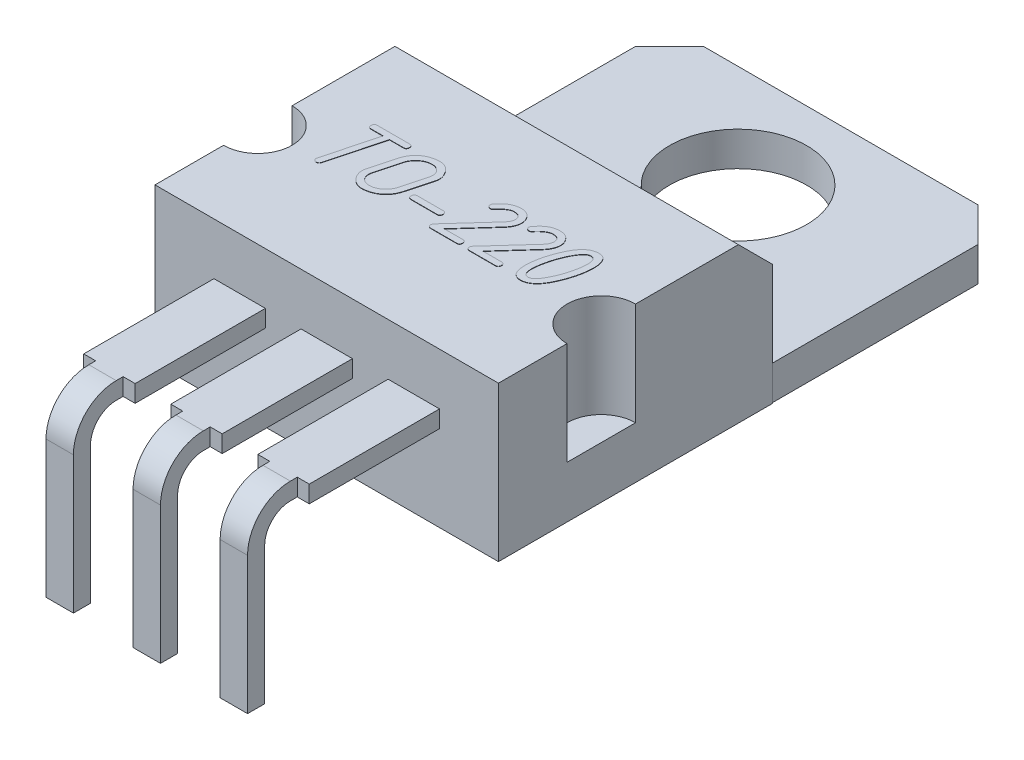
from build123d import *

# Parameters (mm, degrees)
SKETCH_1_R                 = 2
EXTRUDE_1_DEPTH            = 1
EXTRUDE_3_DEPTH            = 1.01
SKETCH_2_5_W               = 10.02
SKETCH_2_5_H               = 8
EXTRUDE_4_DEPTH            = 3.5
SKETCH_3_W                 = 1.5
SKETCH_3_H                 = 0.5
EXTRUDE_5_DEPTH            = 3.8
SKETCH_4_W                 = 0.8
SKETCH_4_H                 = 0.5
PATTERN_LINEAR_1_COUNT     = 2
PATTERN_LINEAR_1_PITCH     = 2.54
PATTERN_LINEAR_1_COL_COUNT = 2
PATTERN_LINEAR_1_COL_PITCH = 2.54
EXTRUDE_6_DEPTH            = 0.01
CHAMFER_1_SIZE             = 1
SKETCH_9_R                 = 1
CUT_EXTRUDE_1_DEPTH        = 3


with BuildPart() as part:
    # Sketch 1 → Extrude 1 (new body)
    with BuildSketch(Plane(origin=(0, 0, 0), x_dir=(1, 0, 0), z_dir=(0, 1, 0))):
        Polygon((0, 0), (8, 0), (8, 6), (9, 6), (9, 12), (8, 13), (0, 13), (-1, 12), (-1, 6), (0, 6), align=None)
        with Locations(Location((4, 10, 0), (0, 0, 270))):
            Circle(SKETCH_1_R, mode=Mode.SUBTRACT)
    extrude(amount=EXTRUDE_1_DEPTH)

    # Sketch 2 → Extrude 3 (add)
    with BuildSketch(Plane(origin=(0, 1, 0), x_dir=(1, 0, 0), z_dir=(0, 1, 0))):
        Polygon((0, 6), (-1.01, 6), (-1.01, -2), (9.01, -2), (9.01, 6), (8, 6), (8, 0), (0, 0), align=None)
    extrude(amount=-EXTRUDE_3_DEPTH)

    # Sketch 2_5 → Extrude 4 (add)
    with BuildSketch(Plane(origin=(0, 1, 0), x_dir=(1, 0, 0), z_dir=(0, 1, 0))):
        with Locations((4, 2)):
            Rectangle(SKETCH_2_5_W, SKETCH_2_5_H)
    extrude(amount=EXTRUDE_4_DEPTH)

    # Sketch 3 → Extrude 5 (add)
    with BuildSketch(Plane.XY.offset(2)):
        with Locations((4, 2.74)):
            Rectangle(SKETCH_3_W, SKETCH_3_H)
    extrude_5 = extrude(amount=EXTRUDE_5_DEPTH)

    # Sweep 1: sweep along a path in Sketch 7
    with BuildLine(Plane.ZY.offset(-4)) as sweep_1_path:
        Line((5.8, 2.74), (6, 2.74))
        ThreePointArc((6, 2.74), (6.707106781, 2.447106781), (7, 1.74))
        Line((7, 1.74), (7, -2.26))
    # Sketch 4 → Sweep 1 (sweep)
    with BuildSketch(Plane.XY.offset(5.8)):
        with Locations((4, 2.74)):
            Rectangle(SKETCH_4_W, SKETCH_4_H)
    sweep_1 = sweep(path=sweep_1_path.line)

    # Pattern Linear 1: Extrude 5, Sweep 1 ×2
    with Locations(*[(-i * PATTERN_LINEAR_1_PITCH, 0, 0) for i in range(1, PATTERN_LINEAR_1_COUNT)]):
        add(extrude_5)
        add(sweep_1)

    # Pattern Linear 1 col: Extrude 5, Sweep 1 ×2
    with Locations(*[(i * PATTERN_LINEAR_1_COL_PITCH, 0, 0) for i in range(1, PATTERN_LINEAR_1_COL_COUNT)]):
        add(extrude_5)
        add(sweep_1)

    # Sketch 8 → Extrude 6 (add)
    with BuildSketch(Plane(origin=(0, 4.5, 0), x_dir=(1, 0, 0), z_dir=(0, 1, 0))):
        with BuildLine():
            Line((1.27858567, 2.5547293), (0.859157599, 0.985020757))
            add(Edge.make_bspline(
                [(0.859157599, 0.985020757), (0.855633438, 0.974783342), (0.849087007, 0.955766466), (0.829278615, 0.93328717), (0.803143513, 0.919336806), (0.783409322, 0.918209838), (0.773079427, 0.917619925)],
                knots=[0, 0, 0, 0, 1.086908555, 2.019025704, 2.963055697, 4, 4, 4, 4], degree=3))
            add(Edge.make_bspline(
                [(0.773079427, 0.917619925), (0.767204868, 0.917864101), (0.755608941, 0.918346085), (0.739020981, 0.924335999), (0.722879767, 0.932189694), (0.708692809, 0.944021025), (0.696472399, 0.957627118), (0.687400283, 0.972740133), (0.681742621, 0.98896155), (0.681188277, 1.000135496), (0.680910819, 1.005728242)],
                knots=[0, 0, 0, 0, 0.998523784, 1.971008786, 2.984412935, 4.053273998, 5.101682541, 6.096988731, 7.047511114, 8, 8, 8, 8], degree=3))
            add(Edge.make_bspline(
                [(0.680910819, 1.005728242), (0.681174471, 1.010217201), (0.681723788, 1.019569906), (0.684127251, 1.028627792), (0.685377139, 1.033338221)],
                knots=[0, 0, 0, 0, 0.959927375, 2, 2, 2, 2], degree=3))
            Line((0.685377139, 1.033338221), (1.091000221, 2.5547293))
            Line((1.091000221, 2.5547293), (0.740191069, 2.5547293))
            add(Edge.make_bspline(
                [(0.740191069, 2.5547293), (0.733142702, 2.555099355), (0.719732405, 2.555803425), (0.700802325, 2.559454679), (0.685008305, 2.567050286), (0.671761457, 2.577083859), (0.661525267, 2.59022733), (0.654625853, 2.606462916), (0.650032952, 2.625124331), (0.649779441, 2.638611333), (0.649646577, 2.645679821)],
                knots=[0, 0, 0, 0, 1.152245291, 2.192274096, 3.121243949, 3.987402553, 4.884564444, 5.804293213, 6.849238333, 8, 8, 8, 8], degree=3))
            add(Edge.make_bspline(
                [(0.649646577, 2.645679821), (0.649743167, 2.652894625), (0.649924046, 2.66640549), (0.654831047, 2.685073251), (0.661247518, 2.701465446), (0.672068578, 2.714215792), (0.684731012, 2.72490292), (0.701007181, 2.73161686), (0.719625863, 2.736254033), (0.733119241, 2.736500939), (0.740191069, 2.736630341)],
                knots=[0, 0, 0, 0, 1.171153265, 2.193170214, 3.131774486, 4.010381834, 4.888989181, 5.807411693, 6.850872717, 8, 8, 8, 8], degree=3))
            Line((0.740191069, 2.736630341), (1.677306257, 2.736630341))
            add(Edge.make_bspline(
                [(1.677306257, 2.736630341), (1.684378085, 2.736500939), (1.697871463, 2.736254033), (1.716490145, 2.73161686), (1.732766314, 2.72490292), (1.745428748, 2.714215792), (1.756249808, 2.701465446), (1.762666279, 2.685073251), (1.76757328, 2.66640549), (1.767754159, 2.652894625), (1.767850749, 2.645679821)],
                knots=[0, 0, 0, 0, 1.149127283, 2.192588307, 3.111010819, 3.989618166, 4.868225514, 5.806829786, 6.828846735, 8, 8, 8, 8], degree=3))
            add(Edge.make_bspline(
                [(1.767850749, 2.645679821), (1.767717885, 2.638611333), (1.767464374, 2.625124331), (1.762871473, 2.606462916), (1.755972059, 2.59022733), (1.745735869, 2.577083859), (1.732489021, 2.567050286), (1.716695001, 2.559454679), (1.697764921, 2.555803425), (1.684354624, 2.555099355), (1.677306257, 2.5547293)],
                knots=[0, 0, 0, 0, 1.150761667, 2.195706787, 3.115435556, 4.012597447, 4.878756051, 5.807725904, 6.847754709, 8, 8, 8, 8], degree=3))
            Line((1.677306257, 2.5547293), (1.27858567, 2.5547293))
        make_face()
        with BuildLine():
            add(Edge.make_bspline(
                [(2.795104399, 1.46332305), (2.786928876, 1.435359174), (2.770956207, 1.380725643), (2.737010598, 1.304094516), (2.697657346, 1.233771974), (2.651951592, 1.169746038), (2.599331694, 1.112551879), (2.539870738, 1.062550924), (2.474692985, 1.018271023), (2.42702941, 0.995393666), (2.402880278, 0.98380267)],
                knots=[0, 0, 0, 0, 1.08866662, 2.126947775, 3.126561852, 4.09871457, 5.062408504, 6.024945022, 6.999322605, 8, 8, 8, 8], degree=3))
            add(Edge.make_bspline(
                [(2.402880278, 0.98380267), (2.378313867, 0.973613917), (2.329126592, 0.953213826), (2.251070685, 0.932898784), (2.170000672, 0.919735969), (2.114653013, 0.918331963), (2.086583601, 0.917619925)],
                knots=[0, 0, 0, 0, 0.979423391, 1.961017766, 2.965935817, 4, 4, 4, 4], degree=3))
            add(Edge.make_bspline(
                [(2.086583601, 0.917619925), (2.068099229, 0.918506111), (2.031082888, 0.920280766), (1.97641298, 0.933954309), (1.922785348, 0.955983), (1.889641331, 0.977040177), (1.872606259, 0.987862961)],
                knots=[0, 0, 0, 0, 0.969629375, 1.941755521, 2.942121495, 4, 4, 4, 4], degree=3))
            add(Edge.make_bspline(
                [(1.872606259, 0.987862961), (1.857284238, 0.999280668), (1.826674514, 1.02209051), (1.785994525, 1.06285397), (1.749783225, 1.108138787), (1.718218433, 1.157282587), (1.692723202, 1.209468583), (1.673769115, 1.263195678), (1.662388069, 1.318163482), (1.660964025, 1.355132764), (1.660253034, 1.373590616)],
                knots=[0, 0, 0, 0, 1.002747793, 2.003249617, 3.014831478, 4.044394242, 5.065129976, 6.059016044, 7.03091446, 8, 8, 8, 8], degree=3))
            add(Edge.make_bspline(
                [(1.660253034, 1.373590616), (1.660698514, 1.389217442), (1.661561083, 1.419475189), (1.668068975, 1.449031367), (1.67121582, 1.46332305)],
                knots=[0, 0, 0, 0, 1.03291398, 2, 2, 2, 2], degree=3))
            Line((1.67121582, 1.46332305), (1.865703764, 2.190927216))
            add(Edge.make_bspline(
                [(1.865703764, 2.190927216), (1.873980736, 2.218847582), (1.890156577, 2.273412876), (1.922695379, 2.350666683), (1.962400108, 2.420860805), (2.008013489, 2.48481578), (2.060378407, 2.542062832), (2.119197819, 2.592682947), (2.184616777, 2.636704017), (2.232178681, 2.659899905), (2.256303769, 2.671665684)],
                knots=[0, 0, 0, 0, 1.088804569, 2.127871211, 3.127611952, 4.099887855, 5.06028041, 6.022379573, 6.996880622, 8, 8, 8, 8], degree=3))
            add(Edge.make_bspline(
                [(2.256303769, 2.671665684), (2.28087072, 2.681727254), (2.330193321, 2.701927677), (2.408420464, 2.72172286), (2.489621465, 2.734416018), (2.544940948, 2.73588505), (2.573006476, 2.736630341)],
                knots=[0, 0, 0, 0, 0.977386569, 1.962280486, 2.966192936, 4, 4, 4, 4], degree=3))
            add(Edge.make_bspline(
                [(2.573006476, 2.736630341), (2.591746407, 2.735993457), (2.628638946, 2.734739649), (2.682372216, 2.722836434), (2.733257287, 2.704088958), (2.781151244, 2.677835473), (2.825952793, 2.644012243), (2.867342026, 2.602481363), (2.906375224, 2.553851), (2.928562719, 2.517251409), (2.940056792, 2.498291253)],
                knots=[0, 0, 0, 0, 0.975824583, 1.921066047, 2.854300508, 3.795318588, 4.757785637, 5.770664113, 6.845108518, 8, 8, 8, 8], degree=3))
            add(Edge.make_bspline(
                [(2.940056792, 2.498291253), (2.949664431, 2.480804137), (2.968482767, 2.44655239), (2.987087534, 2.391882215), (2.999876632, 2.337151111), (3.001143817, 2.300220739), (3.001773217, 2.281877737)],
                knots=[0, 0, 0, 0, 1.049868008, 2.056360327, 3.034610701, 4, 4, 4, 4], degree=3))
            add(Edge.make_bspline(
                [(3.001773217, 2.281877737), (3.001347839, 2.266649752), (3.000489053, 2.235906277), (2.993247154, 2.20601342), (2.989592343, 2.190927216)],
                knots=[0, 0, 0, 0, 0.99064829, 2, 2, 2, 2], degree=3))
            Line((2.989592343, 2.190927216), (2.795104399, 1.46332305))
        make_face()
        with BuildLine():
            Line((2.607112921, 1.46332305), (2.802006894, 2.190927216))
            add(Edge.make_bspline(
                [(2.802006894, 2.190927216), (2.80566221, 2.205740875), (2.812805325, 2.234689311), (2.813734214, 2.264486387), (2.814187767, 2.279035533)],
                knots=[0, 0, 0, 0, 1.023451362, 2, 2, 2, 2], degree=3))
            add(Edge.make_bspline(
                [(2.814187767, 2.279035533), (2.813910445, 2.292204149), (2.81337161, 2.317790639), (2.80594266, 2.354669122), (2.795395541, 2.389232321), (2.779053093, 2.420693911), (2.759166618, 2.449888457), (2.734406398, 2.476202822), (2.704894397, 2.499356146), (2.682929831, 2.51234242), (2.671671549, 2.518998738)],
                knots=[0, 0, 0, 0, 1.07079464, 2.080543449, 3.053262812, 4.004823275, 4.955872695, 5.923015894, 6.935409288, 8, 8, 8, 8], degree=3))
            add(Edge.make_bspline(
                [(2.671671549, 2.518998738), (2.660309844, 2.524636747), (2.637648961, 2.535881738), (2.600940628, 2.546359094), (2.562895324, 2.553879108), (2.536774468, 2.554442407), (2.523470924, 2.5547293)],
                knots=[0, 0, 0, 0, 0.986514322, 1.967599494, 2.964883452, 4, 4, 4, 4], degree=3))
            add(Edge.make_bspline(
                [(2.523470924, 2.5547293), (2.506112298, 2.554192164), (2.471723503, 2.553128058), (2.421146577, 2.544354378), (2.372272589, 2.529973084), (2.324988204, 2.509979398), (2.279265417, 2.484180699), (2.235286078, 2.452624973), (2.192758886, 2.415580175), (2.166846217, 2.387305477), (2.153578404, 2.372828258)],
                knots=[0, 0, 0, 0, 0.978320997, 1.938130408, 2.884772499, 3.845794787, 4.826494249, 5.838756166, 6.893399279, 8, 8, 8, 8], degree=3))
            add(Edge.make_bspline(
                [(2.153578404, 2.372828258), (2.141840253, 2.358750626), (2.118952051, 2.331300673), (2.09124937, 2.286035237), (2.068351634, 2.239751663), (2.058539163, 2.207063639), (2.053695243, 2.190927216)],
                knots=[0, 0, 0, 0, 1.049505148, 2.046428436, 3.035620582, 4, 4, 4, 4], degree=3))
            Line((2.053695243, 2.190927216), (1.859207299, 1.46332305))
            add(Edge.make_bspline(
                [(1.859207299, 1.46332305), (1.855588248, 1.448506838), (1.848513748, 1.419544194), (1.847241708, 1.38976164), (1.846620396, 1.375214733)],
                knots=[0, 0, 0, 0, 1.023125607, 2, 2, 2, 2], degree=3))
            add(Edge.make_bspline(
                [(1.846620396, 1.375214733), (1.846811631, 1.365319636), (1.847187947, 1.345847842), (1.851415929, 1.317435937), (1.857948174, 1.290399276), (1.866717956, 1.264665272), (1.878752068, 1.240568789), (1.893037066, 1.217738129), (1.909657568, 1.196007067), (1.935701123, 1.169789067), (1.972439451, 1.1414982), (2.022636045, 1.117325398), (2.077576397, 1.102060677), (2.115985772, 1.100382758), (2.135713123, 1.099520966)],
                knots=[0, 0, 0, 0, 0.796530066, 1.567429791, 2.307814666, 3.035325116, 3.7520546, 4.472010561, 5.202537203, 5.950349672, 7.443986541, 8.911614415, 10.41378132, 12, 12, 12, 12], degree=3))
            add(Edge.make_bspline(
                [(2.135713123, 1.099520966), (2.153069709, 1.100064994), (2.187454462, 1.101142755), (2.238227588, 1.109844502), (2.287313795, 1.124733988), (2.33495014, 1.144965901), (2.380781946, 1.171441743), (2.425095527, 1.203115286), (2.46777056, 1.240869371), (2.49382504, 1.269522512), (2.50722976, 1.284264212)],
                knots=[0, 0, 0, 0, 0.971607698, 1.924830837, 2.874400901, 3.838768323, 4.816476348, 5.832365049, 6.884777637, 8, 8, 8, 8], degree=3))
            add(Edge.make_bspline(
                [(2.50722976, 1.284264212), (2.518932365, 1.298363945), (2.541797296, 1.325912465), (2.569799469, 1.370576857), (2.592279365, 1.416090353), (2.602220536, 1.44774482), (2.607112921, 1.46332305)],
                knots=[0, 0, 0, 0, 1.062692188, 2.076322643, 3.053293563, 4, 4, 4, 4], degree=3))
        make_face(mode=Mode.SUBTRACT)
        with BuildLine():
            Line((3.852404204, 1.359379597), (3.104092553, 1.359379597))
            add(Edge.make_bspline(
                [(3.104092553, 1.359379597), (3.097044186, 1.359749652), (3.083633889, 1.360453722), (3.064703809, 1.364104977), (3.048909789, 1.371700583), (3.035662941, 1.381734156), (3.02542675, 1.394877628), (3.018527337, 1.411113214), (3.013934435, 1.429774628), (3.013680925, 1.443261631), (3.013548061, 1.450330118)],
                knots=[0, 0, 0, 0, 1.152245291, 2.192274096, 3.121243949, 3.987402553, 4.884564444, 5.804293213, 6.849238333, 8, 8, 8, 8], degree=3))
            add(Edge.make_bspline(
                [(3.013548061, 1.450330118), (3.01364465, 1.457544923), (3.013825529, 1.471055788), (3.01873253, 1.489723548), (3.025149002, 1.506115744), (3.035970061, 1.518866089), (3.048632495, 1.529553217), (3.064908664, 1.536267158), (3.083527346, 1.540904331), (3.097020724, 1.541151237), (3.104092553, 1.541280639)],
                knots=[0, 0, 0, 0, 1.171153265, 2.193170214, 3.131774486, 4.010381834, 4.888989181, 5.807411693, 6.850872717, 8, 8, 8, 8], degree=3))
            Line((3.104092553, 1.541280639), (3.852404204, 1.541280639))
            add(Edge.make_bspline(
                [(3.852404204, 1.541280639), (3.859476032, 1.541151237), (3.87296941, 1.540904331), (3.891588092, 1.536267158), (3.907864261, 1.529553217), (3.920526695, 1.518866089), (3.931347755, 1.506115744), (3.937764226, 1.489723548), (3.942671227, 1.471055788), (3.942852106, 1.457544923), (3.942948696, 1.450330118)],
                knots=[0, 0, 0, 0, 1.149127283, 2.192588307, 3.111010819, 3.989618166, 4.868225514, 5.806829786, 6.828846735, 8, 8, 8, 8], degree=3))
            add(Edge.make_bspline(
                [(3.942948696, 1.450330118), (3.942815832, 1.443261631), (3.942562321, 1.429774628), (3.93796942, 1.411113214), (3.931070006, 1.394877628), (3.920833816, 1.381734156), (3.907586968, 1.371700583), (3.891792948, 1.364104977), (3.872862868, 1.360453722), (3.859452571, 1.359749652), (3.852404204, 1.359379597)],
                knots=[0, 0, 0, 0, 1.150761667, 2.195706787, 3.115435556, 4.012597447, 4.878756051, 5.807725904, 6.847754709, 8, 8, 8, 8], degree=3))
        make_face()
        with BuildLine():
            add(Edge.make_bspline(
                [(4.549556187, 2.315984183), (4.54514884, 2.311040073), (4.536507867, 2.30134673), (4.520338463, 2.290491966), (4.501951989, 2.284214916), (4.489105062, 2.28347348), (4.482561384, 2.283095825)],
                knots=[0, 0, 0, 0, 1.025040379, 2.009677726, 2.986214628, 4, 4, 4, 4], degree=3))
            add(Edge.make_bspline(
                [(4.482561384, 2.283095825), (4.476565014, 2.283363955), (4.464731042, 2.283893115), (4.447840542, 2.289430928), (4.432415678, 2.298339767), (4.418439732, 2.309899507), (4.406631174, 2.323851075), (4.398640456, 2.339670029), (4.392756172, 2.356176446), (4.39226548, 2.367767981), (4.392016892, 2.373640316)],
                knots=[0, 0, 0, 0, 1.01324681, 1.999665296, 2.975361523, 4.017776151, 5.060190779, 6.045008368, 7.009590593, 8, 8, 8, 8], degree=3))
            add(Edge.make_bspline(
                [(4.392016892, 2.373640316), (4.393126861, 2.384079172), (4.39540975, 2.405548924), (4.407652361, 2.423362262), (4.413942464, 2.432514537)],
                knots=[0, 0, 0, 0, 0.972424466, 2, 2, 2, 2], degree=3))
            add(Edge.make_bspline(
                [(4.413942464, 2.432514537), (4.433809877, 2.456597176), (4.4717135, 2.50254273), (4.53051834, 2.564085326), (4.587949377, 2.615302963), (4.628038055, 2.642539487), (4.647003174, 2.655424519)],
                knots=[0, 0, 0, 0, 1.15629407, 2.206011236, 3.151301302, 4, 4, 4, 4], degree=3))
            add(Edge.make_bspline(
                [(4.647003174, 2.655424519), (4.669940338, 2.668096378), (4.715816201, 2.693440943), (4.791616254, 2.718016785), (4.871646986, 2.73425509), (4.926942313, 2.73582742), (4.955179269, 2.736630341)],
                knots=[0, 0, 0, 0, 0.972811039, 1.945687229, 2.950950411, 4, 4, 4, 4], degree=3))
            add(Edge.make_bspline(
                [(4.955179269, 2.736630341), (4.971719815, 2.736063023), (5.004059904, 2.734953802), (5.050985281, 2.726937923), (5.094633848, 2.712692907), (5.135689215, 2.693998989), (5.172699078, 2.668068866), (5.207277154, 2.637930595), (5.23846995, 2.601844933), (5.255720308, 2.574465331), (5.264573451, 2.560413707)],
                knots=[0, 0, 0, 0, 1.060694985, 2.073871789, 3.040117736, 3.999202584, 4.954982404, 5.926671157, 6.935936426, 8, 8, 8, 8], degree=3))
            add(Edge.make_bspline(
                [(5.264573451, 2.560413707), (5.272110813, 2.54637466), (5.287127284, 2.518405064), (5.303188523, 2.473263217), (5.312061128, 2.425691588), (5.313420327, 2.393300429), (5.314109003, 2.376888549)],
                knots=[0, 0, 0, 0, 0.993271713, 1.978867136, 2.97593695, 4, 4, 4, 4], degree=3))
            add(Edge.make_bspline(
                [(5.314109003, 2.376888549), (5.313670752, 2.361425981), (5.31278882, 2.330309224), (5.304599212, 2.283935103), (5.292054706, 2.237626219), (5.273937723, 2.191770002), (5.251172243, 2.145994866), (5.222717329, 2.100932884), (5.189873895, 2.055531216), (5.16466182, 2.026695947), (5.151697359, 2.011868378)],
                knots=[0, 0, 0, 0, 0.906955576, 1.825150615, 2.756077876, 3.719491966, 4.714332584, 5.752697099, 6.844400029, 8, 8, 8, 8], degree=3))
            Line((5.151697359, 2.011868378), (4.325022089, 1.099520966))
            Line((4.325022089, 1.099520966), (4.867476981, 1.099520966))
            add(Edge.make_bspline(
                [(4.867476981, 1.099520966), (4.87454881, 1.099391564), (4.888042187, 1.099144658), (4.906660869, 1.094507485), (4.922937038, 1.087793545), (4.935599472, 1.077106417), (4.946420532, 1.064356071), (4.952837003, 1.047963876), (4.957744004, 1.029296115), (4.957924883, 1.01578525), (4.958021473, 1.008570446)],
                knots=[0, 0, 0, 0, 1.149127283, 2.192588307, 3.111010819, 3.989618166, 4.868225514, 5.806829786, 6.828846735, 8, 8, 8, 8], degree=3))
            add(Edge.make_bspline(
                [(4.958021473, 1.008570446), (4.957888609, 1.001501958), (4.957635098, 0.988014956), (4.953042197, 0.969353541), (4.946142783, 0.953117955), (4.935906593, 0.939974484), (4.922659745, 0.929940911), (4.906865725, 0.922345304), (4.887935645, 0.91869405), (4.874525348, 0.91798998), (4.867476981, 0.917619925)],
                knots=[0, 0, 0, 0, 1.150761667, 2.195706787, 3.115435556, 4.012597447, 4.878756051, 5.807725904, 6.847754709, 8, 8, 8, 8], degree=3))
            Line((4.867476981, 0.917619925), (4.119571359, 0.917619925))
            add(Edge.make_bspline(
                [(4.119571359, 0.917619925), (4.112522992, 0.91798998), (4.099112695, 0.91869405), (4.080182615, 0.922345304), (4.064388595, 0.929940911), (4.051141747, 0.939974484), (4.040905557, 0.953117955), (4.034006143, 0.969353541), (4.029413242, 0.988014956), (4.029159731, 1.001501958), (4.029026867, 1.008570446)],
                knots=[0, 0, 0, 0, 1.152245291, 2.192274096, 3.121243949, 3.987402553, 4.884564444, 5.804293213, 6.849238333, 8, 8, 8, 8], degree=3))
            add(Edge.make_bspline(
                [(4.029026867, 1.008570446), (4.02938093, 1.014414131), (4.030065084, 1.02570584), (4.034219202, 1.042164952), (4.041578247, 1.057356332), (4.048610075, 1.066209992), (4.052170526, 1.0706929)],
                knots=[0, 0, 0, 0, 1.035656384, 2.001190839, 2.987935414, 4, 4, 4, 4], degree=3))
            Line((4.052170526, 1.0706929), (5.020955985, 2.138549461))
            add(Edge.make_bspline(
                [(5.020955985, 2.138549461), (5.029727901, 2.148605786), (5.046756222, 2.168127442), (5.069771421, 2.198146564), (5.088573919, 2.228284838), (5.105059731, 2.257470553), (5.116505883, 2.287051557), (5.125773605, 2.315811437), (5.131305658, 2.344464162), (5.131910182, 2.363467509), (5.132207961, 2.372828258)],
                knots=[0, 0, 0, 0, 1.207518674, 2.344073512, 3.417717558, 4.420571707, 5.371213514, 6.2815554, 7.153521357, 8, 8, 8, 8], degree=3))
            add(Edge.make_bspline(
                [(5.132207961, 2.372828258), (5.131565891, 2.387115136), (5.130347207, 2.414232401), (5.119620842, 2.452124493), (5.101910771, 2.484585456), (5.076162079, 2.510939999), (5.043224202, 2.530829639), (5.003643339, 2.545027625), (4.957149201, 2.553374667), (4.923816581, 2.554258306), (4.906049747, 2.5547293)],
                knots=[0, 0, 0, 0, 1.032884659, 1.960470861, 2.824855343, 3.68433611, 4.595465642, 5.587747212, 6.714229588, 8, 8, 8, 8], degree=3))
            add(Edge.make_bspline(
                [(4.906049747, 2.5547293), (4.897092457, 2.554278227), (4.878607218, 2.553347344), (4.850467274, 2.547440929), (4.821276488, 2.537391382), (4.790952843, 2.523427915), (4.7591295, 2.505895107), (4.726243523, 2.484191715), (4.692192666, 2.458556451), (4.669648282, 2.439531113), (4.65796596, 2.429672334)],
                knots=[0, 0, 0, 0, 0.758958301, 1.566269074, 2.425645627, 3.369876423, 4.391168624, 5.501112665, 6.70509631, 8, 8, 8, 8], degree=3))
            add(Edge.make_bspline(
                [(4.65796596, 2.429672334), (4.638409841, 2.411986976), (4.599465005, 2.376767649), (4.566144718, 2.336187194), (4.549556187, 2.315984183)],
                knots=[0, 0, 0, 0, 1.004298417, 2, 2, 2, 2], degree=3))
        make_face()
        with BuildLine():
            add(Edge.make_bspline(
                [(5.679941232, 2.315984183), (5.675533885, 2.311040073), (5.666892912, 2.30134673), (5.650723508, 2.290491966), (5.632337034, 2.284214916), (5.619490106, 2.28347348), (5.612946429, 2.283095825)],
                knots=[0, 0, 0, 0, 1.025040379, 2.009677726, 2.986214628, 4, 4, 4, 4], degree=3))
            add(Edge.make_bspline(
                [(5.612946429, 2.283095825), (5.606950058, 2.283363955), (5.595116087, 2.283893115), (5.578225586, 2.289430928), (5.562800722, 2.298339767), (5.548824777, 2.309899507), (5.537016219, 2.323851075), (5.529025501, 2.339670029), (5.523141217, 2.356176446), (5.522650524, 2.367767981), (5.522401937, 2.373640316)],
                knots=[0, 0, 0, 0, 1.01324681, 1.999665296, 2.975361523, 4.017776151, 5.060190779, 6.045008368, 7.009590593, 8, 8, 8, 8], degree=3))
            add(Edge.make_bspline(
                [(5.522401937, 2.373640316), (5.523511906, 2.384079172), (5.525794795, 2.405548924), (5.538037405, 2.423362262), (5.544327509, 2.432514537)],
                knots=[0, 0, 0, 0, 0.972424466, 2, 2, 2, 2], degree=3))
            add(Edge.make_bspline(
                [(5.544327509, 2.432514537), (5.564194921, 2.456597176), (5.602098544, 2.50254273), (5.660903384, 2.564085326), (5.718334422, 2.615302963), (5.7584231, 2.642539487), (5.777388218, 2.655424519)],
                knots=[0, 0, 0, 0, 1.15629407, 2.206011236, 3.151301302, 4, 4, 4, 4], degree=3))
            add(Edge.make_bspline(
                [(5.777388218, 2.655424519), (5.800325382, 2.668096378), (5.846201246, 2.693440943), (5.922001299, 2.718016785), (6.002032031, 2.73425509), (6.057327358, 2.73582742), (6.085564314, 2.736630341)],
                knots=[0, 0, 0, 0, 0.972811039, 1.945687229, 2.950950411, 4, 4, 4, 4], degree=3))
            add(Edge.make_bspline(
                [(6.085564314, 2.736630341), (6.102104859, 2.736063023), (6.134444949, 2.734953802), (6.181370326, 2.726937923), (6.225018893, 2.712692907), (6.266074259, 2.693998989), (6.303084122, 2.668068866), (6.337662199, 2.637930595), (6.368854995, 2.601844933), (6.386105353, 2.574465331), (6.394958496, 2.560413707)],
                knots=[0, 0, 0, 0, 1.060694985, 2.073871789, 3.040117736, 3.999202584, 4.954982404, 5.926671157, 6.935936426, 8, 8, 8, 8], degree=3))
            add(Edge.make_bspline(
                [(6.394958496, 2.560413707), (6.402495857, 2.54637466), (6.417512329, 2.518405064), (6.433573568, 2.473263217), (6.442446173, 2.425691588), (6.443805372, 2.393300429), (6.444494048, 2.376888549)],
                knots=[0, 0, 0, 0, 0.993271713, 1.978867136, 2.97593695, 4, 4, 4, 4], degree=3))
            add(Edge.make_bspline(
                [(6.444494048, 2.376888549), (6.444055797, 2.361425981), (6.443173864, 2.330309224), (6.434984257, 2.283935103), (6.42243975, 2.237626219), (6.404322768, 2.191770002), (6.381557288, 2.145994866), (6.353102374, 2.100932884), (6.320258939, 2.055531216), (6.295046865, 2.026695947), (6.282082403, 2.011868378)],
                knots=[0, 0, 0, 0, 0.906955576, 1.825150615, 2.756077876, 3.719491966, 4.714332584, 5.752697099, 6.844400029, 8, 8, 8, 8], degree=3))
            Line((6.282082403, 2.011868378), (5.455407134, 1.099520966))
            Line((5.455407134, 1.099520966), (5.997862026, 1.099520966))
            add(Edge.make_bspline(
                [(5.997862026, 1.099520966), (6.004933854, 1.099391564), (6.018427232, 1.099144658), (6.037045914, 1.094507485), (6.053322083, 1.087793545), (6.065984517, 1.077106417), (6.076805577, 1.064356071), (6.083222048, 1.047963876), (6.088129049, 1.029296115), (6.088309928, 1.01578525), (6.088406517, 1.008570446)],
                knots=[0, 0, 0, 0, 1.149127283, 2.192588307, 3.111010819, 3.989618166, 4.868225514, 5.806829786, 6.828846735, 8, 8, 8, 8], degree=3))
            add(Edge.make_bspline(
                [(6.088406517, 1.008570446), (6.088273653, 1.001501958), (6.088020143, 0.988014956), (6.083427242, 0.969353541), (6.076527828, 0.953117955), (6.066291637, 0.939974484), (6.05304479, 0.929940911), (6.03725077, 0.922345304), (6.01832069, 0.91869405), (6.004910392, 0.91798998), (5.997862026, 0.917619925)],
                knots=[0, 0, 0, 0, 1.150761667, 2.195706787, 3.115435556, 4.012597447, 4.878756051, 5.807725904, 6.847754709, 8, 8, 8, 8], degree=3))
            Line((5.997862026, 0.917619925), (5.249956403, 0.917619925))
            add(Edge.make_bspline(
                [(5.249956403, 0.917619925), (5.242908037, 0.91798998), (5.229497739, 0.91869405), (5.21056766, 0.922345304), (5.19477364, 0.929940911), (5.181526792, 0.939974484), (5.171290601, 0.953117955), (5.164391187, 0.969353541), (5.159798286, 0.988014956), (5.159544776, 1.001501958), (5.159411912, 1.008570446)],
                knots=[0, 0, 0, 0, 1.152245291, 2.192274096, 3.121243949, 3.987402553, 4.884564444, 5.804293213, 6.849238333, 8, 8, 8, 8], degree=3))
            add(Edge.make_bspline(
                [(5.159411912, 1.008570446), (5.159765975, 1.014414131), (5.160450129, 1.02570584), (5.164604246, 1.042164952), (5.171963291, 1.057356332), (5.178995119, 1.066209992), (5.182555571, 1.0706929)],
                knots=[0, 0, 0, 0, 1.035656384, 2.001190839, 2.987935414, 4, 4, 4, 4], degree=3))
            Line((5.182555571, 1.0706929), (6.15134103, 2.138549461))
            add(Edge.make_bspline(
                [(6.15134103, 2.138549461), (6.160112946, 2.148605786), (6.177141267, 2.168127442), (6.200156465, 2.198146564), (6.218958964, 2.228284838), (6.235444776, 2.257470553), (6.246890928, 2.287051557), (6.25615865, 2.315811437), (6.261690702, 2.344464162), (6.262295227, 2.363467509), (6.262593006, 2.372828258)],
                knots=[0, 0, 0, 0, 1.207518674, 2.344073512, 3.417717558, 4.420571707, 5.371213514, 6.2815554, 7.153521357, 8, 8, 8, 8], degree=3))
            add(Edge.make_bspline(
                [(6.262593006, 2.372828258), (6.261950936, 2.387115136), (6.260732252, 2.414232401), (6.250005887, 2.452124493), (6.232295816, 2.484585456), (6.206547124, 2.510939999), (6.173609246, 2.530829639), (6.134028384, 2.545027625), (6.087534246, 2.553374667), (6.054201626, 2.554258306), (6.036434791, 2.5547293)],
                knots=[0, 0, 0, 0, 1.032884659, 1.960470861, 2.824855343, 3.68433611, 4.595465642, 5.587747212, 6.714229588, 8, 8, 8, 8], degree=3))
            add(Edge.make_bspline(
                [(6.036434791, 2.5547293), (6.027477502, 2.554278227), (6.008992263, 2.553347344), (5.980852319, 2.547440929), (5.951661533, 2.537391382), (5.921337887, 2.523427915), (5.889514544, 2.505895107), (5.856628567, 2.484191715), (5.822577711, 2.458556451), (5.800033326, 2.439531113), (5.788351004, 2.429672334)],
                knots=[0, 0, 0, 0, 0.758958301, 1.566269074, 2.425645627, 3.369876423, 4.391168624, 5.501112665, 6.70509631, 8, 8, 8, 8], degree=3))
            add(Edge.make_bspline(
                [(5.788351004, 2.429672334), (5.768794886, 2.411986976), (5.729850049, 2.376767649), (5.696529763, 2.336187194), (5.679941232, 2.315984183)],
                knots=[0, 0, 0, 0, 1.004298417, 2, 2, 2, 2], degree=3))
        make_face()
        with BuildLine():
            add(Edge.make_bspline(
                [(7.26995123, 1.380493111), (7.261036749, 1.361739353), (7.243620983, 1.325101095), (7.2155274, 1.272699464), (7.186658116, 1.223722357), (7.156855591, 1.178343449), (7.125692835, 1.1368012), (7.094356498, 1.098375856), (7.06112043, 1.064300518), (7.027567997, 1.033271377), (6.992953778, 1.005982916), (6.957486359, 0.982168569), (6.920878707, 0.962290547), (6.883291632, 0.945857126), (6.844660362, 0.933236915), (6.805070794, 0.924479368), (6.764772753, 0.918316684), (6.737535043, 0.917853019), (6.723842076, 0.917619925)],
                knots=[0, 0, 0, 0, 1.31396504, 2.567026414, 3.76130175, 4.911102417, 6.000620447, 7.046856242, 8.046363338, 9.010298362, 9.937336866, 10.832938417, 11.710667508, 12.569939145, 13.425874458, 14.277814767, 15.134221374, 16, 16, 16, 16], degree=3))
            add(Edge.make_bspline(
                [(6.723842076, 0.917619925), (6.712043603, 0.917875593), (6.688997729, 0.918374987), (6.655666018, 0.92389175), (6.624447984, 0.932174258), (6.595793028, 0.94467313), (6.569088636, 0.960007049), (6.545050908, 0.979349552), (6.523260991, 1.002022223), (6.503775872, 1.028077184), (6.486787249, 1.057639476), (6.471607726, 1.090300695), (6.459098163, 1.126649269), (6.449192395, 1.166510599), (6.440996555, 1.209597301), (6.435409785, 1.256123205), (6.432252031, 1.306145361), (6.431757091, 1.340697637), (6.431501116, 1.358567539)],
                knots=[0, 0, 0, 0, 0.943365174, 1.842668473, 2.696736533, 3.521664531, 4.337223326, 5.154291285, 5.981633642, 6.848180464, 7.751064454, 8.705803332, 9.72664275, 10.822158527, 11.990591767, 13.23469772, 14.569828524, 16, 16, 16, 16], degree=3))
            add(Edge.make_bspline(
                [(6.431501116, 1.358567539), (6.432256153, 1.39405144), (6.433783821, 1.465846045), (6.444759456, 1.574620508), (6.462727554, 1.685479916), (6.487701457, 1.79862019), (6.519419556, 1.914122935), (6.558539821, 2.031852488), (6.604892132, 2.151848599), (6.64039114, 2.231543214), (6.658471389, 2.272133039)],
                knots=[0, 0, 0, 0, 0.897758864, 1.816436179, 2.763400626, 3.738072067, 4.746655979, 5.79277328, 6.875821826, 8, 8, 8, 8], degree=3))
            add(Edge.make_bspline(
                [(6.658471389, 2.272133039), (6.667363495, 2.291033677), (6.684686077, 2.327853735), (6.713030195, 2.380389326), (6.741635729, 2.429656868), (6.771589172, 2.475079375), (6.802703164, 2.516661002), (6.834208766, 2.555061229), (6.86716095, 2.589543332), (6.900870992, 2.620558828), (6.935468748, 2.647855662), (6.970921811, 2.671709991), (7.007648201, 2.691451525), (7.04502543, 2.708497983), (7.083776495, 2.720981008), (7.123348015, 2.729779553), (7.163650833, 2.735931386), (7.190887899, 2.736396512), (7.204580543, 2.736630341)],
                knots=[0, 0, 0, 0, 1.319636362, 2.570764398, 3.770565317, 4.918591966, 6.006428988, 7.051050555, 8.055189273, 9.017637049, 9.943245234, 10.837464969, 11.713839818, 12.575231358, 13.429846054, 14.280471913, 15.135557177, 16, 16, 16, 16], degree=3))
            add(Edge.make_bspline(
                [(7.204580543, 2.736630341), (7.216379014, 2.736374672), (7.239424884, 2.735875275), (7.272756623, 2.730358529), (7.303974557, 2.722075964), (7.332629869, 2.709577294), (7.359332956, 2.694242635), (7.383375572, 2.674902905), (7.405146723, 2.652219584), (7.424776932, 2.626113008), (7.441504965, 2.596266522), (7.45692848, 2.563452876), (7.46923475, 2.526891249), (7.479244435, 2.486933688), (7.487459807, 2.443708561), (7.49298403, 2.397041051), (7.496176236, 2.346887391), (7.496667453, 2.312334737), (7.496921503, 2.29446464)],
                knots=[0, 0, 0, 0, 0.94157855, 1.839178673, 2.691629227, 3.514994908, 4.329009129, 5.144529656, 5.970305123, 6.835210807, 7.745739726, 8.698670439, 9.72779236, 10.821233357, 11.98745372, 13.239934881, 14.572537102, 16, 16, 16, 16], degree=3))
            add(Edge.make_bspline(
                [(7.496921503, 2.29446464), (7.496163219, 2.2589809), (7.494626104, 2.187051904), (7.483658129, 2.078008496), (7.465742379, 1.966867553), (7.440715359, 1.853601094), (7.409007092, 1.738095817), (7.36987225, 1.620372118), (7.323615182, 1.500469931), (7.288043589, 1.420942306), (7.26995123, 1.380493111)],
                knots=[0, 0, 0, 0, 0.897349411, 1.819014657, 2.768926733, 3.743153642, 4.751277556, 5.796917741, 6.879472326, 8, 8, 8, 8], degree=3))
        make_face()
        with BuildLine():
            add(Edge.make_bspline(
                [(7.240717134, 1.827125133), (7.246672221, 1.850100845), (7.258303672, 1.894976911), (7.273045327, 1.961135697), (7.286421856, 2.023961326), (7.29636576, 2.08376385), (7.304560581, 2.140340707), (7.31092922, 2.193783691), (7.314128525, 2.244347763), (7.314729139, 2.27700193), (7.315020461, 2.292840523)],
                knots=[0, 0, 0, 0, 1.204708347, 2.353031385, 3.440362003, 4.464775335, 5.429561101, 6.342257786, 7.195927883, 8, 8, 8, 8], degree=3))
            add(Edge.make_bspline(
                [(7.315020461, 2.292840523), (7.314604882, 2.313298064), (7.313825666, 2.351656169), (7.306847045, 2.405307999), (7.294474996, 2.450918515), (7.277357437, 2.488779596), (7.25441807, 2.518352814), (7.226440978, 2.540106021), (7.192557655, 2.552658853), (7.168411742, 2.554021033), (7.15585705, 2.5547293)],
                knots=[0, 0, 0, 0, 1.421542027, 2.665406307, 3.749512726, 4.696283625, 5.533696846, 6.325766355, 7.129480493, 8, 8, 8, 8], degree=3))
            add(Edge.make_bspline(
                [(7.15585705, 2.5547293), (7.148522036, 2.554411569), (7.13369361, 2.553769247), (7.111560244, 2.548604635), (7.089472794, 2.540400938), (7.067445114, 2.528852599), (7.045270938, 2.514009616), (7.023224145, 2.495667312), (7.000728848, 2.474482064), (6.978459109, 2.449962969), (6.955962542, 2.422261317), (6.934007785, 2.390852233), (6.911001602, 2.356929424), (6.88877943, 2.319159551), (6.866154632, 2.278415578), (6.843355596, 2.23423613), (6.820229996, 2.1870999), (6.805615139, 2.154164726), (6.798145403, 2.137331374)],
                knots=[0, 0, 0, 0, 0.612491105, 1.238208915, 1.889574883, 2.577622769, 3.311734196, 4.115562866, 4.971727362, 5.892411677, 6.881693737, 7.952045055, 9.093996164, 10.306432429, 11.612744315, 12.988840088, 14.460979255, 16, 16, 16, 16], degree=3))
            add(Edge.make_bspline(
                [(6.798145403, 2.137331374), (6.786260352, 2.109548439), (6.763289642, 2.055851261), (6.733823308, 1.975998945), (6.70775106, 1.900696804), (6.69421696, 1.85102368), (6.687705485, 1.827125133)],
                knots=[0, 0, 0, 0, 1.100013242, 2.126039182, 3.098406995, 4, 4, 4, 4], degree=3))
            add(Edge.make_bspline(
                [(6.687705485, 1.827125133), (6.681750398, 1.804149421), (6.670118947, 1.759273355), (6.655377292, 1.693114569), (6.642000763, 1.63028894), (6.632056859, 1.570486416), (6.623862038, 1.513909559), (6.617493399, 1.460466575), (6.614294094, 1.409902503), (6.61369348, 1.377248336), (6.613402158, 1.361409743)],
                knots=[0, 0, 0, 0, 1.204708347, 2.353031385, 3.440362003, 4.464775335, 5.429561101, 6.342257786, 7.195927883, 8, 8, 8, 8], degree=3))
            add(Edge.make_bspline(
                [(6.613402158, 1.361409743), (6.613744879, 1.340939344), (6.614387802, 1.302538187), (6.622256199, 1.249060256), (6.633811358, 1.203254391), (6.651114167, 1.165503139), (6.674009599, 1.135731048), (6.702256513, 1.114376714), (6.735953354, 1.101500625), (6.759997648, 1.100200526), (6.772565569, 1.099520966)],
                knots=[0, 0, 0, 0, 1.421981532, 2.667546164, 3.749494647, 4.696558264, 5.534230392, 6.33405241, 7.129211351, 8, 8, 8, 8], degree=3))
            add(Edge.make_bspline(
                [(6.772565569, 1.099520966), (6.779900649, 1.099838617), (6.794729208, 1.100480777), (6.816861544, 1.105646639), (6.838953157, 1.113845281), (6.860963925, 1.125414158), (6.88312108, 1.140114138), (6.904804922, 1.158731753), (6.927305504, 1.17974595), (6.949557276, 1.20429056), (6.972032868, 1.232002039), (6.994060968, 1.263274262), (7.016541613, 1.297455294), (7.038843695, 1.335079655), (7.061500227, 1.375742957), (7.083835635, 1.420027323), (7.106507417, 1.467244278), (7.121154595, 1.500099122), (7.128653099, 1.516918892)],
                knots=[0, 0, 0, 0, 0.613451412, 1.240150266, 1.892537491, 2.581664148, 3.316926567, 4.113279556, 4.970786407, 5.892914236, 6.883747362, 7.955776852, 9.093273158, 10.307610365, 11.61597038, 12.989045516, 14.45856627, 16, 16, 16, 16], degree=3))
            add(Edge.make_bspline(
                [(7.128653099, 1.516918892), (7.140463307, 1.544729814), (7.163376301, 1.598685807), (7.193877255, 1.678252157), (7.219698004, 1.75381406), (7.233870659, 1.803245819), (7.240717134, 1.827125133)],
                knots=[0, 0, 0, 0, 1.098318585, 2.130848777, 3.09705725, 4, 4, 4, 4], degree=3))
        make_face(mode=Mode.SUBTRACT)
    extrude(amount=EXTRUDE_6_DEPTH)

    # Chamfer 1
    chamfer_1_edges = [part.edges().sort_by_distance(p)[0] for p in [
        (4, 4.5, -6),
    ]]
    chamfer(chamfer_1_edges, length=CHAMFER_1_SIZE)

    # Sketch 9 → Cut-Extrude 1 (cut)
    with BuildSketch(Plane(origin=(0, 4.5, 0), x_dir=(1, 0, 0), z_dir=(0, 1, 0))):
        with Locations((-1.01, 1)):
            Circle(SKETCH_9_R)
        with Locations((9.01, 1)):
            Circle(SKETCH_9_R)
    extrude(amount=-CUT_EXTRUDE_1_DEPTH, mode=Mode.SUBTRACT)


solid = part.part
